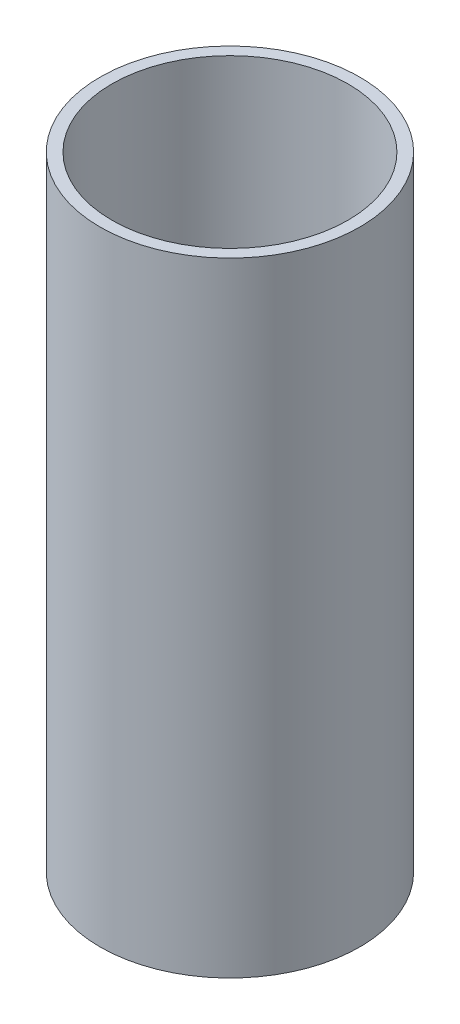
from build123d import *

# Parameters (mm, degrees)
SKETCH_1_R      = 55
SKETCH_1_R_2    = 50
EXTRUDE_1_DEPTH = 264


with BuildPart() as part:
    # 草图1 → 凸台-拉伸1 (new body)
    with BuildSketch(Plane(origin=(0, 0, 0), x_dir=(1, 0, 0), z_dir=(0, 1, 0))):
        Circle(SKETCH_1_R)
        Circle(SKETCH_1_R_2, mode=Mode.SUBTRACT)
    extrude(amount=EXTRUDE_1_DEPTH)


solid = part.part
